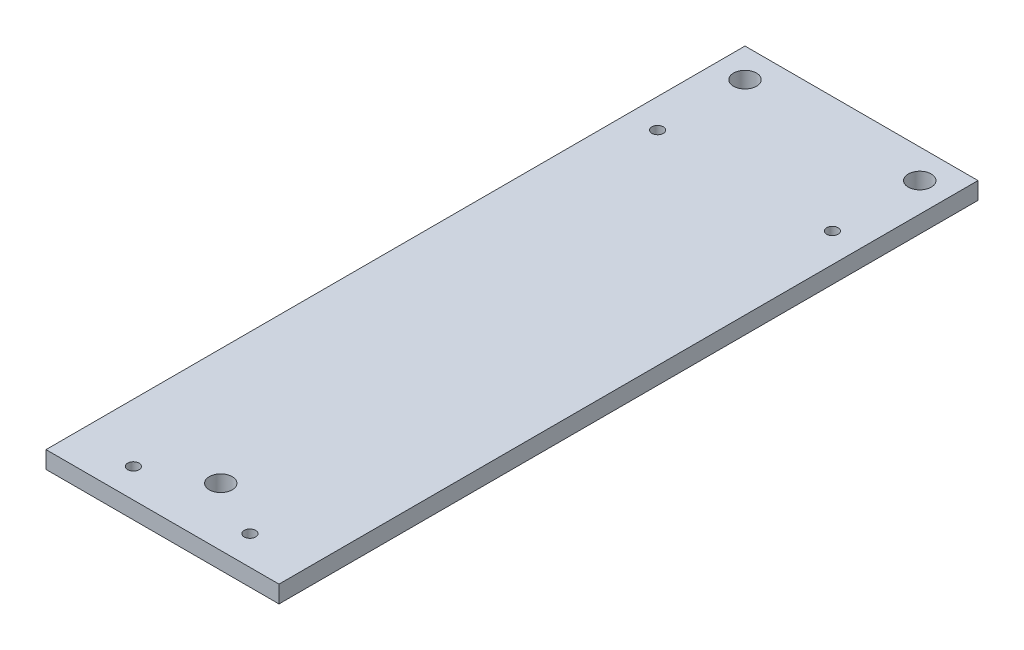
from build123d import *

# Parameters (mm, degrees)
SKETCH1_W           = 20.32
SKETCH1_H           = 60.96
SKETCH1_R           = 0.5
SKETCH1_R_2         = 1
BOSS_EXTRUDE1_DEPTH = 1.5


with BuildPart() as part:
    # Sketch1 → Boss-Extrude1 (new body)
    with BuildSketch(Plane(origin=(0, 0, 0), x_dir=(1, 0, 0), z_dir=(0, 1, 0))):
        with Locations((35.56, -45.72)):
            Rectangle(SKETCH1_W, SKETCH1_H)
        with Locations(Location((30.48, -73.66, 0), (0, 0, 270))):  # turned: the seam where the file's is
            Circle(SKETCH1_R, mode=Mode.SUBTRACT)
        with Locations(Location((35.56, -71.12, 0), (0, 0, 270))):  # turned: the seam where the file's is
            Circle(SKETCH1_R_2, mode=Mode.SUBTRACT)
        with Locations(Location((40.64, -73.66, 0), (0, 0, 270))):  # turned: the seam where the file's is
            Circle(SKETCH1_R, mode=Mode.SUBTRACT)
        with Locations(Location((27.94, -25.4, 0), (0, 0, 270))):  # turned: the seam where the file's is
            Circle(SKETCH1_R, mode=Mode.SUBTRACT)
        with Locations(Location((27.94, -17.78, 0), (0, 0, 270))):  # turned: the seam where the file's is
            Circle(SKETCH1_R_2, mode=Mode.SUBTRACT)
        with Locations(Location((43.18, -25.4, 0), (0, 0, 270))):  # turned: the seam where the file's is
            Circle(SKETCH1_R, mode=Mode.SUBTRACT)
        with Locations(Location((43.18, -17.78, 0), (0, 0, 270))):  # turned: the seam where the file's is
            Circle(SKETCH1_R_2, mode=Mode.SUBTRACT)
    extrude(amount=BOSS_EXTRUDE1_DEPTH)


solid = part.part
